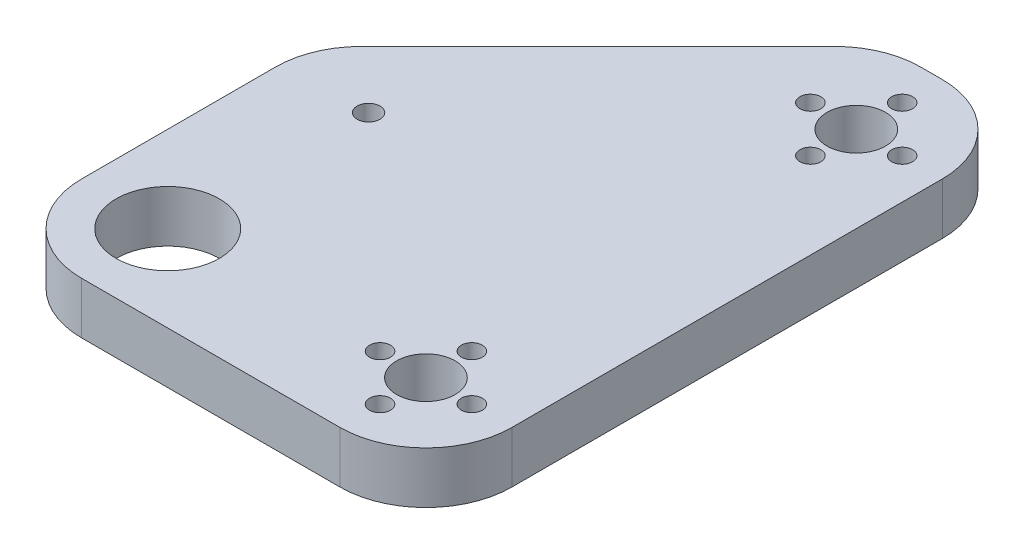
from build123d import *

# Parameters (mm, degrees)
SKETCH1_W           = 75
SKETCH1_H           = 105
BOSS_EXTRUDE1_DEPTH = 9
SKETCH2_R           = 9
SKETCH2_R_2         = 2
SKETCH2_R_3         = 5.1
SKETCH2_R_4         = 1.825
CUT_EXTRUDE1_DEPTH  = 9
CHAMFER1_SIZE       = 50
FILLET1_R           = 15


with BuildPart() as part:
    # Sketch1 → Boss-Extrude1 (new body)
    with BuildSketch(Plane(origin=(0, 0, 0), x_dir=(1, 0, 0), z_dir=(0, 1, 0))):
        with Locations((37.5, 52.5)):
            Rectangle(SKETCH1_W, SKETCH1_H)
    extrude(amount=BOSS_EXTRUDE1_DEPTH)

    # Sketch2 → Cut-Extrude1 (cut)
    with BuildSketch(Plane(origin=(0, 9, 0), x_dir=(1, 0, 0), z_dir=(0, 1, 0))):
        with Locations((15, 15)):
            Circle(SKETCH2_R)
        with Locations((15, 50)):
            Circle(SKETCH2_R_2)
        with Locations((60, 15)):
            Circle(SKETCH2_R_3)
        with Locations((60, 23)):
            Circle(SKETCH2_R_4)
        with Locations((60, 7)):
            Circle(SKETCH2_R_4)
        with Locations((68, 15)):
            Circle(SKETCH2_R_4)
        with Locations((52, 15)):
            Circle(SKETCH2_R_4)
        with Locations((60, 90)):
            Circle(SKETCH2_R_3)
        with Locations((60, 98)):
            Circle(SKETCH2_R_4)
        with Locations((60, 82)):
            Circle(SKETCH2_R_4)
        with Locations((68, 90)):
            Circle(SKETCH2_R_4)
        with Locations((52, 90)):
            Circle(SKETCH2_R_4)
    extrude(amount=-CUT_EXTRUDE1_DEPTH, mode=Mode.SUBTRACT)

    # Chamfer1
    chamfer1_edges = [part.edges().sort_by_distance(p)[0] for p in [
        (0, 4.5, -105),
    ]]
    chamfer(chamfer1_edges, length=CHAMFER1_SIZE)

    # Fillet1
    fillet1_edges = [part.edges().sort_by_distance(p)[0] for p in [
        (0, 4.5, -55),
        (50, 4.5, -105),
        (75, 4.5, -105),
        (75, 4.5, 0),
        (0, 4.5, 0),
    ]]
    fillet(fillet1_edges, radius=FILLET1_R)


solid = part.part
